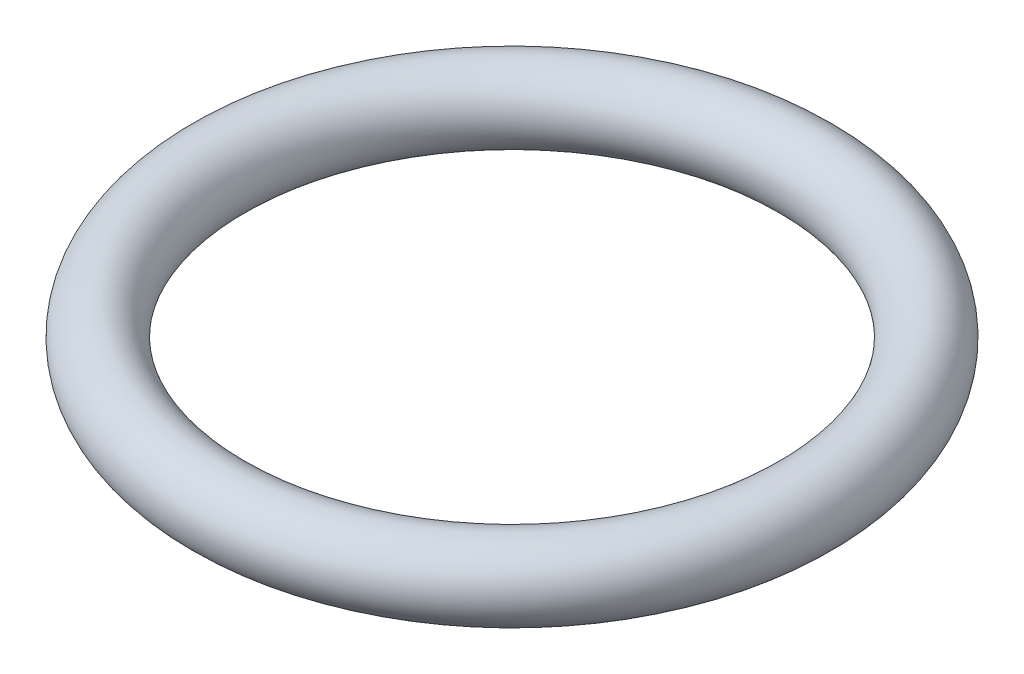
from build123d import *

# Parameters (mm, degrees)
SKETCH1_R = 0.79375


with BuildPart() as part:
    # Sketch1 → Revolve1 (revolve)
    with BuildSketch(Plane.XY, mode=Mode.PRIVATE) as revolve1_sk:
        with Locations((-6.35, 0)):
            Circle(SKETCH1_R)
    revolve(revolve1_sk.sketch.rotate(Axis((0, 0, 0), (0, 1, 0)), 270), axis=Axis((0, 0, 0), (0, 1, 0)))  # turned: the seam where the file's is


solid = part.part
